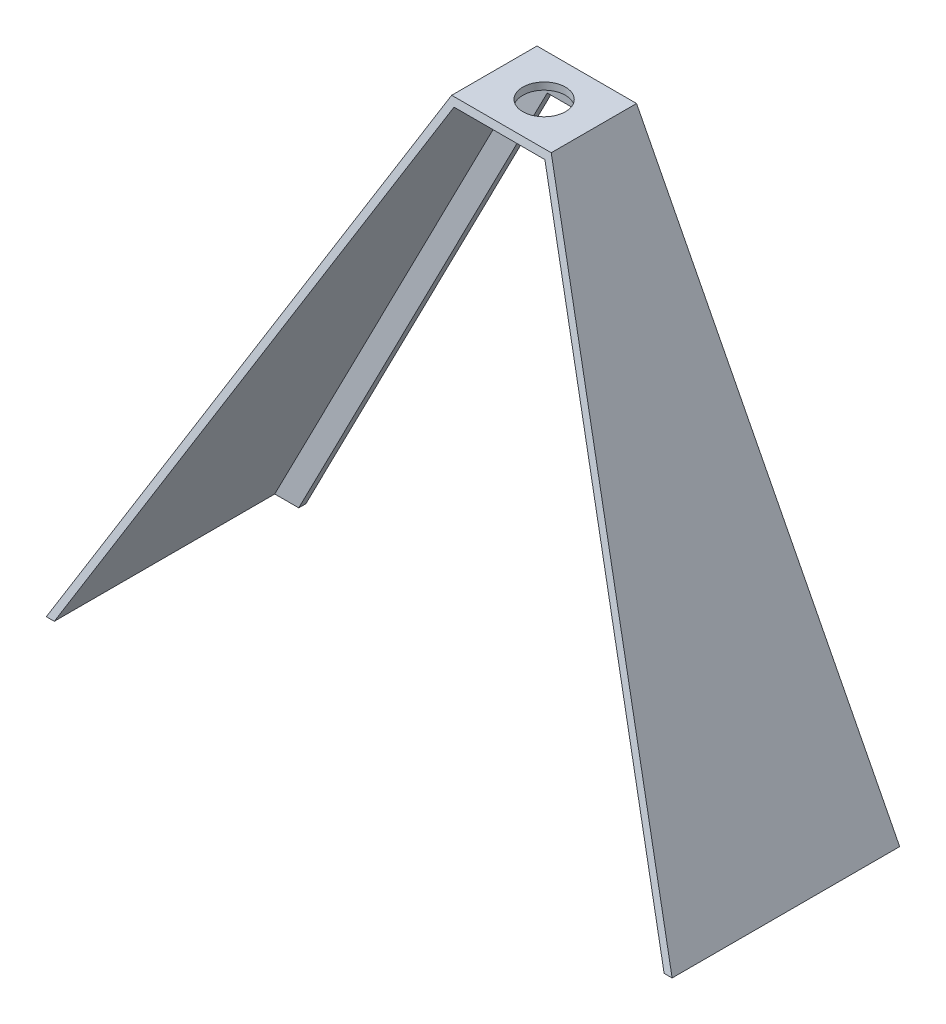
from build123d import *

# Parameters (mm, degrees)
BOSS_EXTRUDE1_DEPTH     = 203.2
CUT_EXTRUDE1_DEPTH      = 280.4
CUT_EXTRUDE1_DEPTH_BACK = 280.4
SHELL1_T                = -6.35
CUT_EXTRUDE2_DEPTH      = 204.2
SKETCH4_R               = 19.05
CUT_EXTRUDE3_DEPTH      = 458.2


with BuildPart() as part:
    # Sketch1 → Boss-Extrude1 (new body)
    with BuildSketch(Plane.XY):
        Polygon((-279.4, 0), (-44.45, 457.2), (44.45, 457.2), (279.4, 0), align=None)
    extrude(amount=BOSS_EXTRUDE1_DEPTH)

    # Sketch2 → Cut-Extrude1 (cut, two sides)
    with BuildSketch(Plane(origin=(0, 0, 0), x_dir=(0, 0, -1), z_dir=(1, 0, 0))) as cut_extrude1_sk:
        Polygon((-203.2, 0), (-76.2, 457.2), (-203.2, 457.2), align=None)
    extrude(amount=CUT_EXTRUDE1_DEPTH, mode=Mode.SUBTRACT)
    extrude(cut_extrude1_sk.sketch, amount=-CUT_EXTRUDE1_DEPTH_BACK, mode=Mode.SUBTRACT)

    # Shell1
    shell1_openings = [part.faces().sort_by_distance(p)[0] for p in [
        (0, 228.6, 139.7),
        (0, 0, 101.6),
    ]]
    offset(amount=SHELL1_T, openings=shell1_openings, kind=Kind.INTERSECTION)

    # Sketch3 → Cut-Extrude2 (cut, through all)
    with BuildSketch(Plane(origin=(0, 0, 0), x_dir=(-1, 0, 0), z_dir=(0, 0, -1))):
        Polygon((250.842426439, 0), (28.945204216, 431.8), (-28.945204216, 431.8), (-250.842426439, 0), align=None)
    extrude(amount=-CUT_EXTRUDE2_DEPTH, mode=Mode.SUBTRACT)

    # Sketch4 → Cut-Extrude3 (cut, through all)
    with BuildSketch(Plane(origin=(0, 457.2, 0), x_dir=(1, 0, 0), z_dir=(0, 1, 0))):
        with Locations((0, -38.1)):
            Circle(SKETCH4_R)
    extrude(amount=-CUT_EXTRUDE3_DEPTH, mode=Mode.SUBTRACT)


solid = part.part
